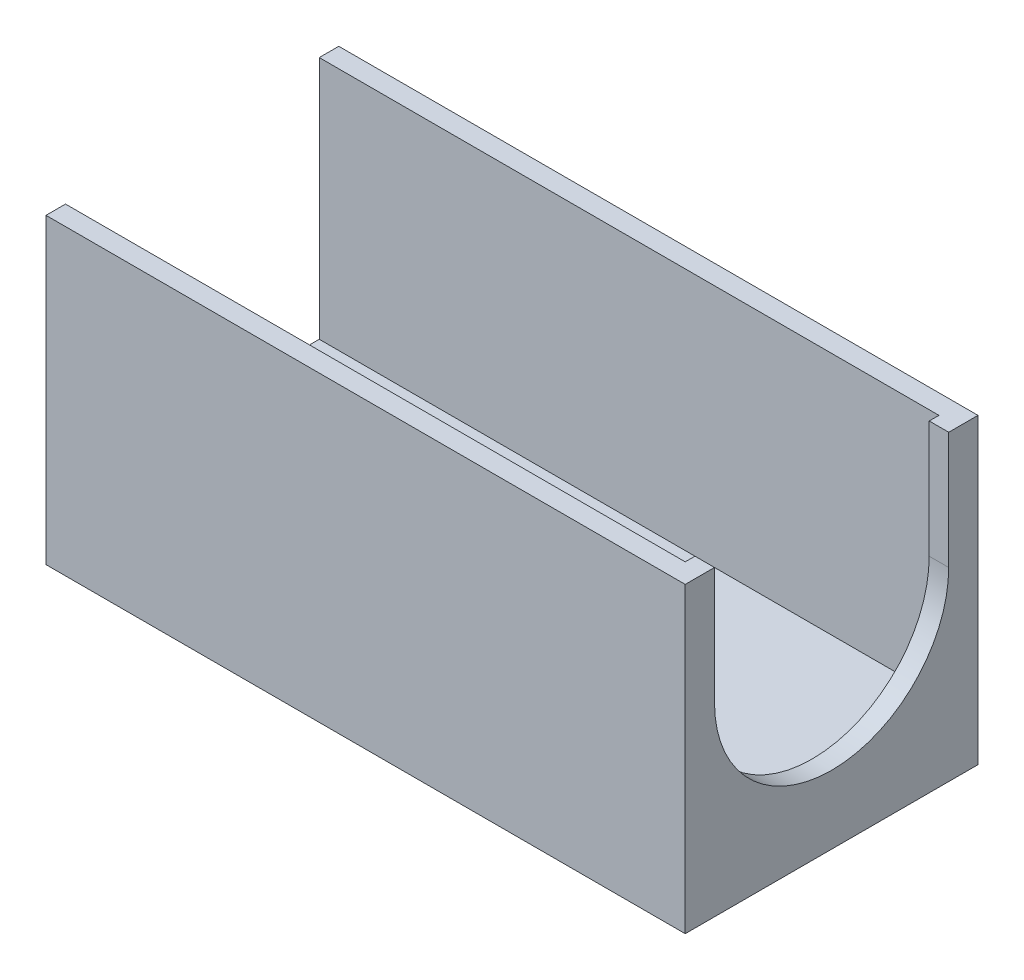
from build123d import *

# Parameters (mm, degrees)
SKETCH1_W           = 66
SKETCH1_H           = 30
BOSS_EXTRUDE1_DEPTH = 31
SKETCH2_W           = 64
SKETCH2_H           = 26
CUT_EXTRUDE1_DEPTH  = 25
SKETCH3_R           = 1
BOSS_EXTRUDE2_DEPTH = 30
SKETCH4_W           = 6
SKETCH4_H           = 6
CUT_EXTRUDE2_DEPTH  = 8.25
SKETCH5_W           = 6
SKETCH5_H           = 6
CUT_EXTRUDE3_DEPTH  = 8.25
SKETCH6_W           = 0.5
SKETCH6_H           = 8.25
CUT_EXTRUDE4_DEPTH  = 31
CUT_EXTRUDE5_DEPTH  = 2


with BuildPart() as part:
    # Sketch1 → Boss-Extrude1 (new body)
    with BuildSketch(Plane(origin=(0, 0, 0), x_dir=(1, 0, 0), z_dir=(0, 1, 0))):
        Rectangle(SKETCH1_W, SKETCH1_H)
    extrude(amount=BOSS_EXTRUDE1_DEPTH)

    # Sketch2 → Cut-Extrude1 (cut)
    with BuildSketch(Plane(origin=(0, 31, 0), x_dir=(1, 0, 0), z_dir=(0, 1, 0))):
        with Locations((-1, 0)):
            Rectangle(SKETCH2_W, SKETCH2_H)
    extrude(amount=-CUT_EXTRUDE1_DEPTH, mode=Mode.SUBTRACT)

    # Sketch3 → Boss-Extrude2 (add)
    with BuildSketch(Plane.XY.offset(15)):
        with BuildLine():
            Line((-36, 0), (-33, 0))
            Line((-33, 0), (-33, 6))
            Line((-33, 6), (-36, 6))
            ThreePointArc((-36, 6), (-39, 3), (-36, 0))
        make_face()
        with Locations((-36, 3)):
            Circle(SKETCH3_R, mode=Mode.SUBTRACT)
    extrude(amount=-BOSS_EXTRUDE2_DEPTH)

    # Sketch4 → Cut-Extrude2 (cut)
    with BuildSketch(Plane.XY.offset(15)):
        with Locations((-36, 3)):
            Rectangle(SKETCH4_W, SKETCH4_H)
    extrude(amount=-CUT_EXTRUDE2_DEPTH, mode=Mode.SUBTRACT)

    # Sketch5 → Cut-Extrude3 (cut)
    with BuildSketch(Plane(origin=(0, 0, -15), x_dir=(-1, 0, 0), z_dir=(0, 0, -1))):
        with Locations((36, 3)):
            Rectangle(SKETCH5_W, SKETCH5_H)
    extrude(amount=-CUT_EXTRUDE3_DEPTH, mode=Mode.SUBTRACT)

    # Sketch6 → Cut-Extrude4 (cut)
    with BuildSketch(Plane.XZ):
        with Locations((-32.75, -10.875)):
            Rectangle(SKETCH6_W, SKETCH6_H)
        with Locations((-32.75, 10.875)):
            Rectangle(SKETCH6_W, SKETCH6_H)
    extrude(amount=-CUT_EXTRUDE4_DEPTH, mode=Mode.SUBTRACT)

    # Sketch7 → Cut-Extrude5 (cut)
    with BuildSketch(Plane(origin=(33, 0, 0), x_dir=(0, 0, -1), z_dir=(1, 0, 0))):
        with BuildLine():
            Line((12, 19), (12, 31))
            Line((12, 31), (-12, 31))
            Line((-12, 31), (-12, 19))
            ThreePointArc((-12, 19), (0, 7), (12, 19))
        make_face()
    extrude(amount=-CUT_EXTRUDE5_DEPTH, mode=Mode.SUBTRACT)


solid = part.part
